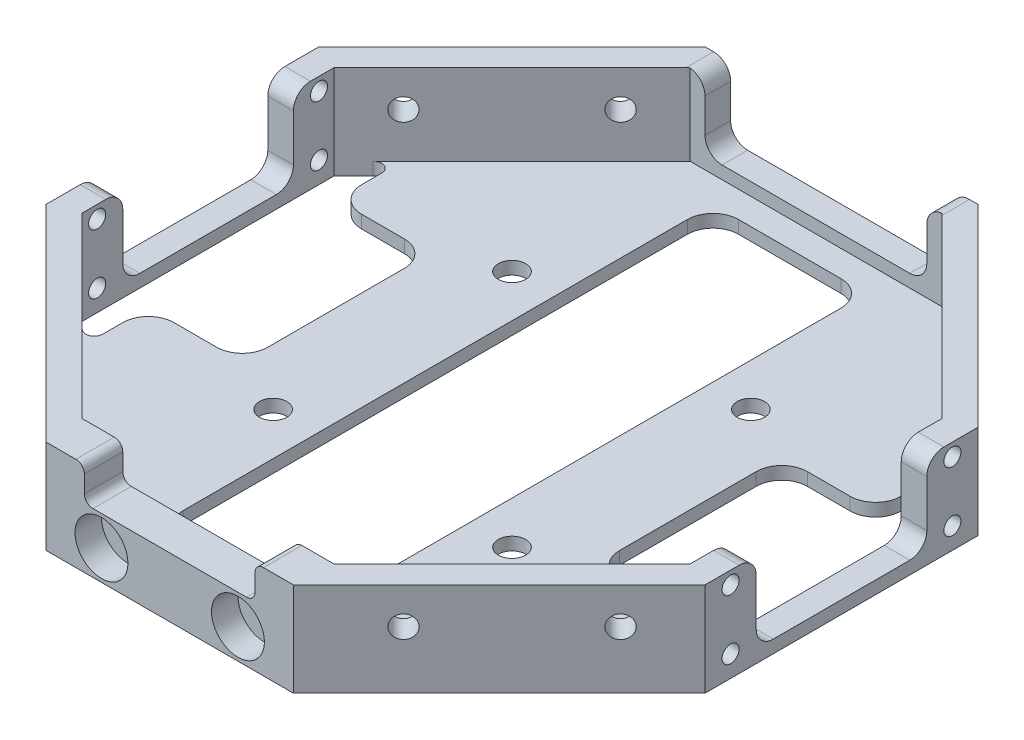
from build123d import *

# Parameters (mm, degrees)
BOSS_EXTRUDE1_DEPTH      = 11
SHELL1_T                 = -3
SHELL1_THICKNESS_2_DEPTH = 1.5
SKETCH2_R                = 1.3
CUT_EXTRUDE1_DEPTH       = 152
SKETCH3_R                = 1.3
CUT_EXTRUDE2_DEPTH       = 152
CUT_EXTRUDE3_DEPTH       = 152
SKETCH5_W                = 13
SKETCH5_H                = 8
CUT_EXTRUDE4_DEPTH       = 45
FILLET1_R                = 2
CUT_EXTRUDE6_DEPTH       = 92
SKETCH6_R                = 1
CUT_EXTRUDE7_DEPTH       = 5
SKETCH12_R               = 1
CUT_EXTRUDE8_DEPTH       = 5
FILLET2_R                = 1
BOSS_EXTRUDE2_DEPTH      = 11
SKETCH14_R               = 3.1
CUT_EXTRUDE9_DEPTH       = 3.1
CUT_EXTRUDE10_DEPTH      = 9.1
FILLET3_R                = 1
SKETCH19_R               = 1.6
CUT_EXTRUDE12_DEPTH      = 10
FILLET4_R                = 3


with BuildPart() as part:
    # Sketch1 → Boss-Extrude1 (new body)
    with BuildSketch(Plane(origin=(0, 0, 0), x_dir=(1, 0, 0), z_dir=(0, 1, 0))):
        Polygon((38.627416998, 16), (16, 38.627416998), (-16, 38.627416998), (-38.627416998, 16), (-38.627416998, -16), (-16, -38.627416998), (16, -38.627416998), (38.627416998, -16), align=None)
    extrude(amount=BOSS_EXTRUDE1_DEPTH)

    # Shell1
    shell1_openings = [part.faces().sort_by_distance(p)[0] for p in [
        (0, 11, 0),
    ]]
    offset(amount=SHELL1_T, openings=shell1_openings, kind=Kind.INTERSECTION)

    # Shell1 thickness 2 face (on inner face of the shell) → Shell1 thickness 2 (cut)
    with BuildSketch(Plane(origin=(0, 3, 0), x_dir=(0, 0, -1), z_dir=(0, -1, 0))):
        Polygon((-14.757359313, 35.627416998), (14.757359313, 35.627416998), (35.627416998, 14.757359313), (35.627416998, -14.757359313), (14.757359313, -35.627416998), (-14.757359313, -35.627416998), (-35.627416998, -14.757359313), (-35.627416998, 14.757359313), align=None)
    extrude(amount=SHELL1_THICKNESS_2_DEPTH, mode=Mode.SUBTRACT)

    # Sketch2 → Cut-Extrude1 (cut)
    with BuildSketch(Plane(origin=(27.313708499, 0, 27.313708499), x_dir=(0.7071067811865475, 0, -0.7071067811865477), z_dir=(0.7071067811865477, 0, 0.7071067811865475))):
        with Locations((9, 6.75)):
            Circle(SKETCH2_R)
        with Locations((-9, 6.75)):
            Circle(SKETCH2_R)
    extrude(amount=-CUT_EXTRUDE1_DEPTH, mode=Mode.SUBTRACT)

    # Sketch3 → Cut-Extrude2 (cut)
    with BuildSketch(Plane(origin=(-27.313708499, 0, 27.313708499), x_dir=(0.7071067811865476, 0, 0.7071067811865476), z_dir=(-0.7071067811865476, 0, 0.7071067811865476))):
        with Locations((9, 6.75)):
            Circle(SKETCH3_R)
        with Locations((-9, 6.75)):
            Circle(SKETCH3_R)
    extrude(amount=-CUT_EXTRUDE2_DEPTH, mode=Mode.SUBTRACT)

    # Sketch4 → Cut-Extrude3 (cut)
    with BuildSketch(Plane(origin=(38.627416998, 0, 0), x_dir=(0, 0, -1), z_dir=(1, 0, 0))):
        Polygon((0, 1.5), (10, 1.5), (10, 11), (0, 11), (-10, 11), (-10, 1.5), align=None)
    extrude(amount=-CUT_EXTRUDE3_DEPTH, mode=Mode.SUBTRACT)

    # Sketch5 → Cut-Extrude4 (cut)
    with BuildSketch(Plane(origin=(0, 0, -38.627416998), x_dir=(-1, 0, 0), z_dir=(0, 0, -1))):
        with Locations((-6.5, 7)):
            Rectangle(SKETCH5_W, SKETCH5_H)
        with Locations((6.5, 7)):
            Rectangle(SKETCH5_W, SKETCH5_H)
    extrude(amount=-CUT_EXTRUDE4_DEPTH, mode=Mode.SUBTRACT)

    # Fillet1
    fillet1_edges = [part.edges().sort_by_distance(p)[0] for p in [
        (-13, 11, -37.127416998),
        (-13, 3, -37.127416998),
        (13, 11, -37.127416998),
        (13, 3, -37.127416998),
        (37.127416998, 11, 10),
        (37.127416998, 1.5, 10),
        (37.127416998, 11, -10),
        (37.127416998, 1.5, -10),
        (-37.127416998, 11, -10),
        (-37.127416998, 1.5, -10),
        (-37.127416998, 11, 10),
        (-37.127416998, 1.5, 10),
    ]]
    fillet(fillet1_edges, radius=FILLET1_R)

    # Sketch7 → Cut-Extrude6 (cut)
    with BuildSketch(Plane(origin=(0, 1.5, 0), x_dir=(1, 0, 0), z_dir=(0, 1, 0))):
        Polygon((35.627416998, -10.000000003), (31.627416998, -10.000000003), (31.627416998, -18.757359313), (35.627416998, -14.757359313), align=None)
        Polygon((35.627416998, 14.757359313), (35.627416998, 10.000000003), (31.627416998, 10.000000003), (31.627416998, 18.757359313), align=None)
        Polygon((-35.627416998, 10.000000003), (-31.627416998, 10.000000003), (-31.627416998, 18.757359313), (-35.627416998, 14.757359313), align=None)
        Polygon((-35.627416998, -14.757359313), (-35.627416998, -10.000000003), (-31.627416998, -10.000000003), (-31.627416998, -18.757359313), align=None)
    extrude(amount=-CUT_EXTRUDE6_DEPTH, mode=Mode.SUBTRACT)

    # Sketch6 → Cut-Extrude7 (cut)
    with BuildSketch(Plane(origin=(38.627416998, 0, 0), x_dir=(0, 0, -1), z_dir=(1, 0, 0))):
        with Locations((-13, 9.5)):
            Circle(SKETCH6_R)
        with Locations((-13, 2.5)):
            Circle(SKETCH6_R)
        with Locations((13, 2.5)):
            Circle(SKETCH6_R)
        with Locations((13, 9.5)):
            Circle(SKETCH6_R)
    extrude(amount=-CUT_EXTRUDE7_DEPTH, mode=Mode.SUBTRACT)

    # Sketch12 → Cut-Extrude8 (cut)
    with BuildSketch(Plane(origin=(-35.627416998, 0, 0), x_dir=(0, 0, -1), z_dir=(1, 0, 0))):
        with Locations((-13, 9.5)):
            Circle(SKETCH12_R)
        with Locations((-13, 2.5)):
            Circle(SKETCH12_R)
        with Locations((13, 2.5)):
            Circle(SKETCH12_R)
        with Locations((13, 9.5)):
            Circle(SKETCH12_R)
    extrude(amount=-CUT_EXTRUDE8_DEPTH, mode=Mode.SUBTRACT)

    # Fillet2
    fillet2_edges = [part.edges().sort_by_distance(p)[0] for p in [
        (-31.627416998, 0.75, 10.000000003),
        (-31.627416998, 0.75, 18.757359313),
        (-35.627416998, 0.75, 10.000000003),
        (35.627416998, 0.75, -10.000000003),
        (31.627416998, 0.75, -10.000000003),
        (31.627416998, 0.75, -18.757359313),
        (31.627416998, 0.75, 10.000000003),
        (35.627416998, 0.75, 10.000000003),
        (31.627416998, 0.75, 18.757359313),
        (-31.627416998, 0.75, -10.000000003),
        (-35.627416998, 0.75, -10.000000003),
        (-31.627416998, 0.75, -18.757359313),
    ]]
    fillet(fillet2_edges, radius=FILLET2_R)

    # Sketch13 → Boss-Extrude2 (add)
    with BuildSketch(Plane(origin=(0, 11, 0), x_dir=(1, 0, 0), z_dir=(0, 1, 0))):
        Polygon((0, -38.627416998), (-16, -38.627416998), (-14.5, -40.127416998), (0, -40.127416998), align=None)
        Polygon((16, -38.627416998), (0, -38.627416998), (0, -40.127416998), (14.5, -40.127416998), align=None)
    extrude(amount=-BOSS_EXTRUDE2_DEPTH)

    # Sketch14 → Cut-Extrude9 (cut)
    with BuildSketch(Plane.XY.offset(40.127416998)):
        with Locations((8, 3.5)):
            Circle(SKETCH14_R)
        with Locations((-8, 3.5)):
            Circle(SKETCH14_R)
    extrude(amount=-CUT_EXTRUDE9_DEPTH, mode=Mode.SUBTRACT)

    # Sketch18 → Cut-Extrude10 (cut)
    with BuildSketch(Plane.XY.offset(40.127416998)):
        Polygon((-10, 7), (0, 7), (10, 7), (10, 11), (-10, 11), align=None)
    extrude(amount=-CUT_EXTRUDE10_DEPTH, mode=Mode.SUBTRACT)

    # Fillet3
    fillet3_edges = [part.edges().sort_by_distance(p)[0] for p in [
        (-10, 7, 37.877416998),
        (-10, 11, 37.877416998),
        (10, 11, 37.877416998),
        (10, 7, 37.877416998),
    ]]
    fillet(fillet3_edges, radius=FILLET3_R)

    # Sketch19 → Cut-Extrude12 (cut)
    with BuildSketch(Plane(origin=(0, 0, 0), x_dir=(-1, 0, 0), z_dir=(0, -1, 0))):
        Polygon((9, -32.556349186), (9, 32.556349186), (-9, 32.556349186), (-9, -14), (-9, -32.556349186), align=None)
        with Locations(Location((-14, -14, 0), (0, 0, 90))):
            Circle(SKETCH19_R)
        with BuildLine():
            Line((-35.627416998, -11), (-23.627416998, -11))
            ThreePointArc((-23.627416998, -11), (-21.506096654, -10.121320344), (-20.627416998, -8))
            Line((-20.627416998, -8), (-20.627416998, 7.999999998))
            ThreePointArc((-20.627416998, 7.999999998), (-21.506096654, 10.121320342), (-23.627416998, 10.999999998))
            Line((-23.627416998, 10.999999998), (-35.627416998, 10.999999998))
            Line((-35.627416998, 10.999999998), (-35.627416998, -11))
        make_face()
        with BuildLine():
            Line((35.627416998, 11.000000003), (23.627416998, 11.000000003))
            ThreePointArc((23.627416998, 11.000000003), (21.506096652, 10.121320344), (20.627416998, 7.999999997))
            Line((20.627416998, 7.999999997), (20.627416998, -8.000000003))
            ThreePointArc((20.627416998, -8.000000003), (21.506096654, -10.121320346), (23.627416998, -11.000000003))
            Line((23.627416998, -11.000000003), (35.627416998, -11.000000003))
            Line((35.627416998, -11.000000003), (35.627416998, 11.000000003))
        make_face()
        with Locations(Location((14, -14, 0), (0, 0, 90))):
            Circle(SKETCH19_R)
        with Locations(Location((-14, 14, 0), (0, 0, 90))):
            Circle(SKETCH19_R)
        with Locations(Location((14, 14, 0), (0, 0, 90))):
            Circle(SKETCH19_R)
    extrude(amount=-CUT_EXTRUDE12_DEPTH, mode=Mode.SUBTRACT)

    # Fillet4
    fillet4_edges = [part.edges().sort_by_distance(p)[0] for p in [
        (31.627416998, 0.75, -11.000000003),
        (31.627416998, 0.75, 11.000000003),
        (-31.627416998, 0.75, 11.000000003),
        (-31.627416998, 0.75, -11.000000003),
        (-9, 0.75, 32.556349186),
        (9, 0.75, 32.556349186),
        (9, 0.75, -32.556349186),
        (-9, 0.75, -32.556349186),
    ]]
    fillet(fillet4_edges, radius=FILLET4_R)


solid = part.part
